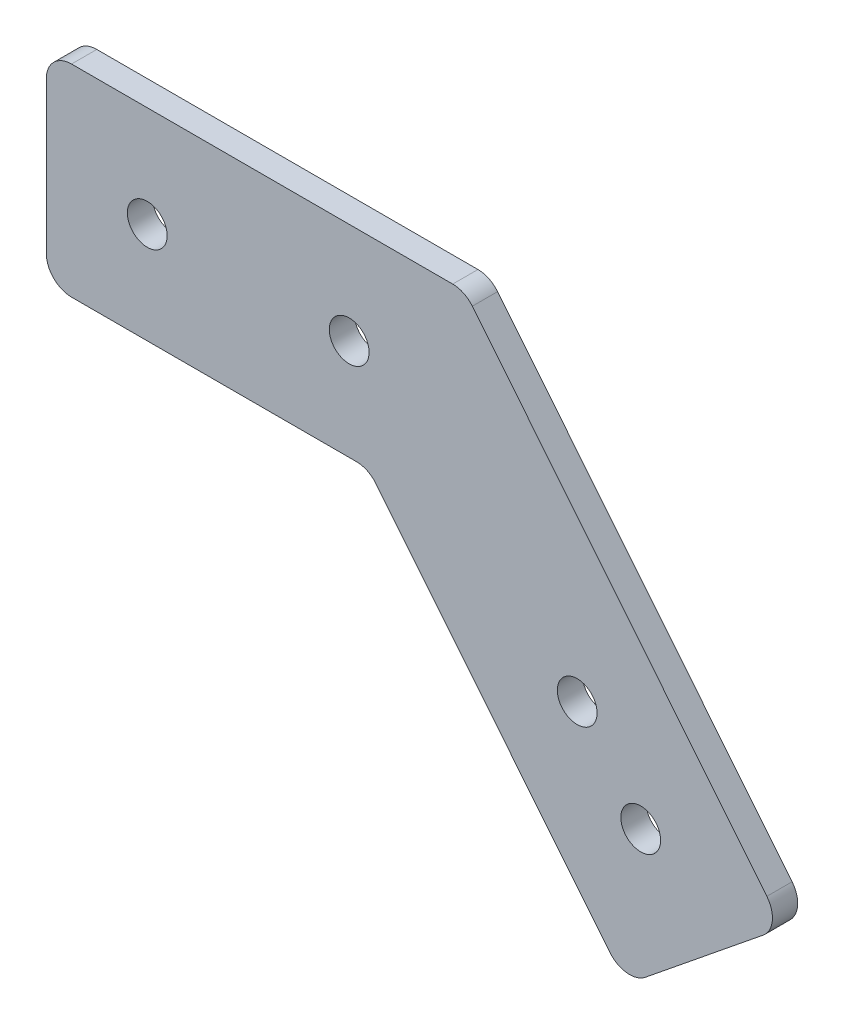
from build123d import *

# Parameters (mm, degrees)
SKETCH1_R           = 2.5019
BOSS_EXTRUDE1_DEPTH = 3.175
FILLET1_R           = 3.175


with BuildPart() as part:
    # Sketch1 → Boss-Extrude1 (new body)
    with BuildSketch(Plane.XY):
        Polygon((50.8, 696.232068306), (72.893120941, 668.941577789), (92.634850884, 684.923570745), (52.636012774, 734.332068306), (0, 734.332068306), (0, 708.932068306), (40.518666443, 708.932068306), align=None)
        with Locations((66.781992956, 696.67430421)):
            Circle(SKETCH1_R, mode=Mode.SUBTRACT)
        with Locations((74.772989434, 686.803439238)):
            Circle(SKETCH1_R, mode=Mode.SUBTRACT)
        with Locations((12.7, 721.632068306)):
            Circle(SKETCH1_R, mode=Mode.SUBTRACT)
        with Locations((38.1, 721.632068306)):
            Circle(SKETCH1_R, mode=Mode.SUBTRACT)
    extrude(amount=BOSS_EXTRUDE1_DEPTH)

    # Fillet1
    fillet1_edges = [part.edges().sort_by_distance(p)[0] for p in [
        (52.636012774, 734.332068306, 1.5875),
        (92.634850884, 684.923570745, 1.5875),
        (72.893120941, 668.941577789, 1.5875),
        (40.518666443, 708.932068306, 1.5875),
        (0, 708.932068306, 1.5875),
        (0, 734.332068306, 1.5875),
    ]]
    fillet(fillet1_edges, radius=FILLET1_R)


solid = part.part
